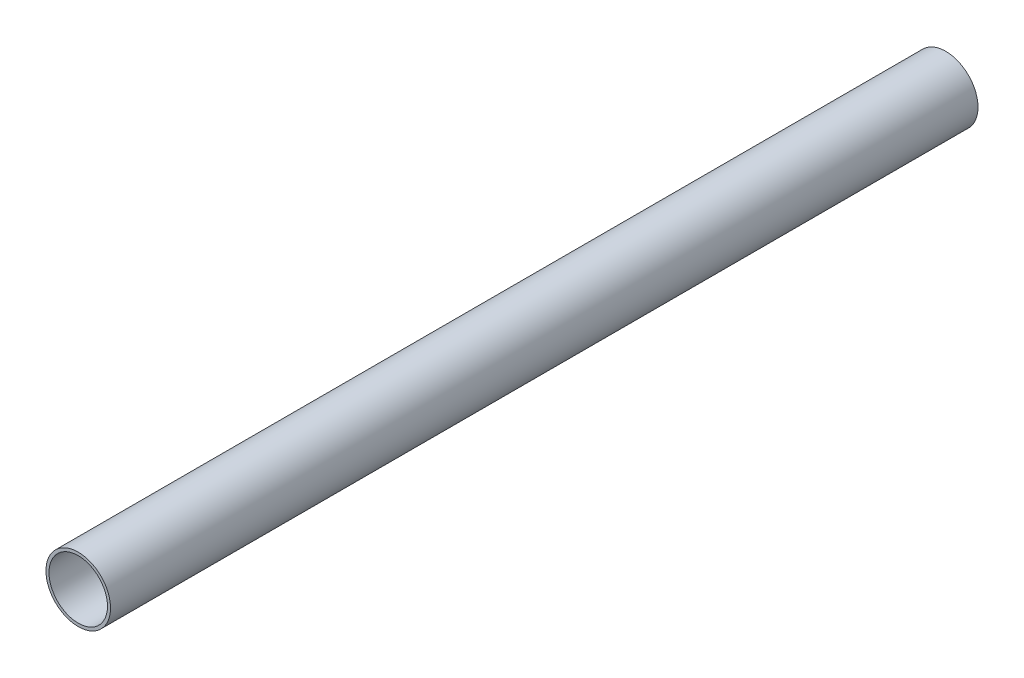
from build123d import *

# Parameters (mm, degrees)
SKETCH_1_R      = 16
SKETCH_1_R_2    = 14.5
EXTRUDE_1_DEPTH = 215


with BuildPart() as part:
    # 草图1 → 凸台-拉伸1 (new body, symmetric)
    with BuildSketch(Plane.XY):
        Circle(SKETCH_1_R)
        Circle(SKETCH_1_R_2, mode=Mode.SUBTRACT)
    extrude(amount=EXTRUDE_1_DEPTH, both=True)


solid = part.part
